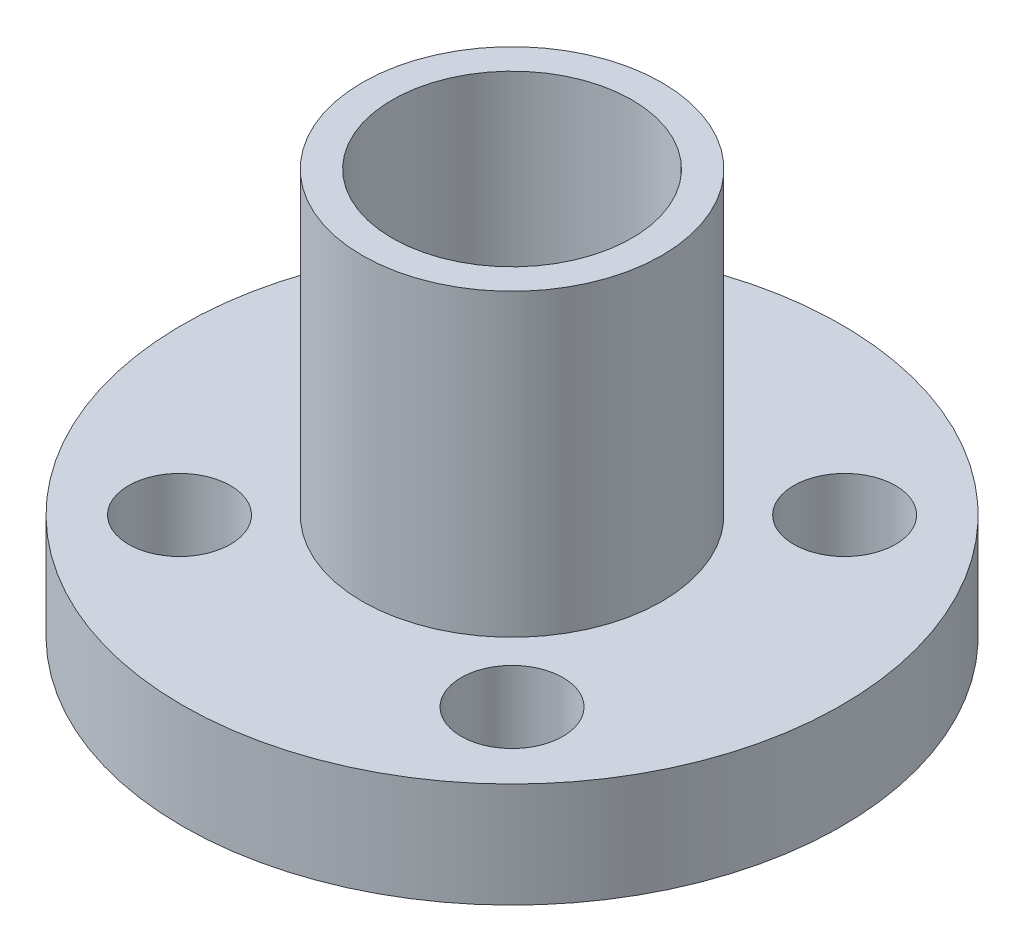
from build123d import *

# Parameters (mm, degrees)
SKETCH1_R           = 11
SKETCH1_R_2         = 4
SKETCH1_R_3         = 1.7
BOSS_EXTRUDE1_DEPTH = 3.5
SKETCH2_R           = 5
BOSS_EXTRUDE2_DEPTH = 10
BOSS_EXTRUDE3_START = -5
SKETCH2_2_R         = 5
BOSS_EXTRUDE3_DEPTH = 5
SKETCH3_R           = 4
CUT_EXTRUDE1_DEPTH  = 20


with BuildPart() as part:
    # Sketch1 → Boss-Extrude1 (new body)
    with BuildSketch(Plane(origin=(0, 0, 0), x_dir=(1, 0, 0), z_dir=(0, 1, 0))):
        with Locations((-13.832754598, -13.4034603)):
            Circle(SKETCH1_R)
        with Locations((-13.832754598, -13.4034603)):
            Circle(SKETCH1_R_2, mode=Mode.SUBTRACT)
        with Locations((-19.382754598, -7.8534603)):
            Circle(SKETCH1_R_3, mode=Mode.SUBTRACT)
        with Locations((-8.282754598, -7.8534603)):
            Circle(SKETCH1_R_3, mode=Mode.SUBTRACT)
        with Locations((-8.282754598, -18.9534603)):
            Circle(SKETCH1_R_3, mode=Mode.SUBTRACT)
        with Locations((-19.382754598, -18.9534603)):
            Circle(SKETCH1_R_3, mode=Mode.SUBTRACT)
    extrude(amount=BOSS_EXTRUDE1_DEPTH)

    # Sketch2 → Boss-Extrude2 (add)
    with BuildSketch(Plane(origin=(0, 3.5, 0), x_dir=(1, 0, 0), z_dir=(0, 1, 0))):
        with Locations((-13.832754598, -13.4034603)):
            Circle(SKETCH2_R)
    extrude(amount=BOSS_EXTRUDE2_DEPTH)

    # Sketch2_2 → Boss-Extrude3 (add)
    with BuildSketch(Plane(origin=(0, 3.5, 0), x_dir=(1, 0, 0), z_dir=(0, 1, 0)).offset(BOSS_EXTRUDE3_START)):
        with Locations((-13.832754598, -13.4034603)):
            Circle(SKETCH2_2_R)
    extrude(amount=BOSS_EXTRUDE3_DEPTH)

    # Sketch3 → Cut-Extrude1 (cut)
    with BuildSketch(Plane(origin=(0, 13.5, 0), x_dir=(1, 0, 0), z_dir=(0, 1, 0))):
        with Locations((-13.832754598, -13.4034603)):
            Circle(SKETCH3_R)
    extrude(amount=-CUT_EXTRUDE1_DEPTH, mode=Mode.SUBTRACT)


solid = part.part
